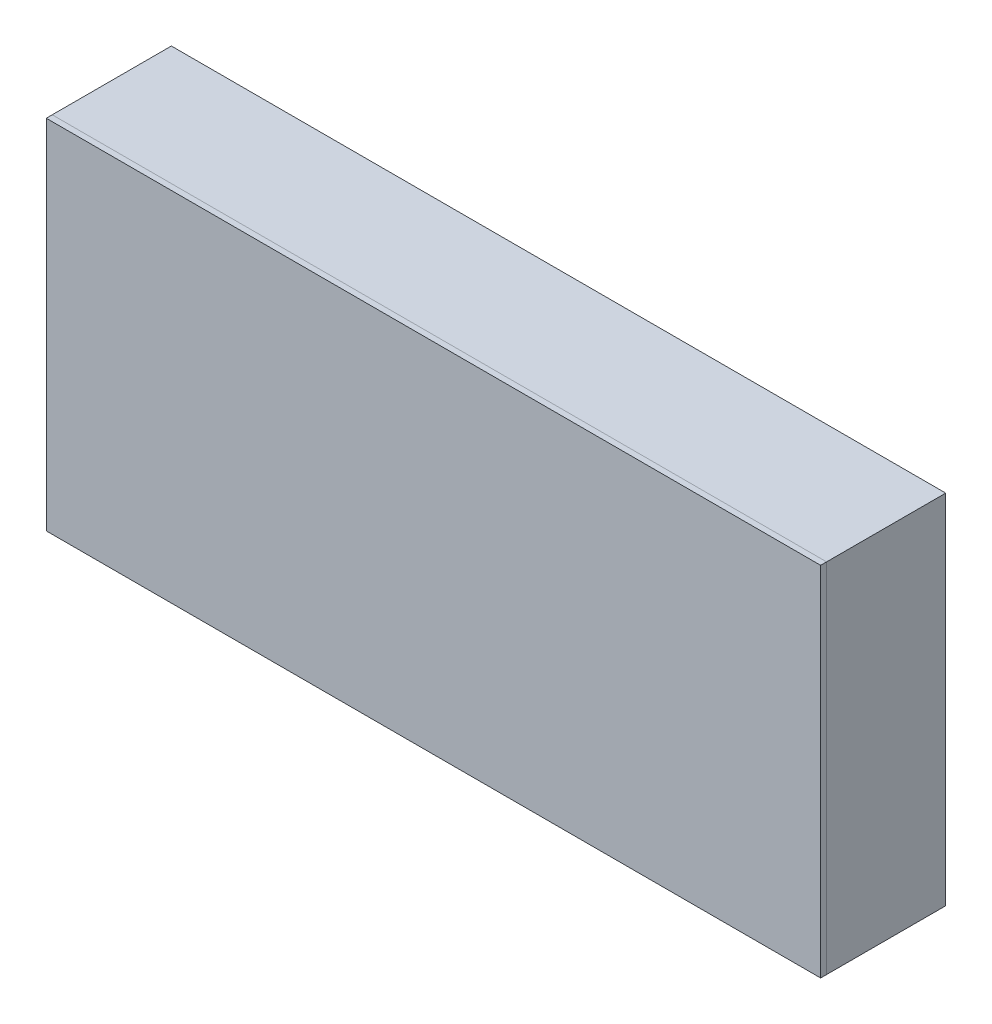
from build123d import *

# Parameters (mm, degrees)
EXTRUDE_THIN1_DEPTH = 20
EXTRUDE_THIN2_DEPTH = 1
SKETCH2_W           = 2
SKETCH2_H           = 17
EXTRUDE_THIN3_DEPTH = 6
BOSS_EXTRUDE1_DEPTH = 2
SKETCH4_W           = 130
SKETCH4_H           = 60
SKETCH4_W_2         = 126
SKETCH4_H_2         = 56
SKETCH4_W_3         = 125.5
SKETCH4_H_3         = 55.5
BOSS_EXTRUDE2_DEPTH = 1
SKETCH4_4_W         = 125.5
SKETCH4_4_H         = 55.5
SKETCH4_4_W_2       = 121.5
SKETCH4_4_H_2       = 51.5
EXTRUDE_THIN4_DEPTH = 5


with BuildPart() as part:
    # Sketch1 → Extrude-Thin1 (new body)
    with BuildSketch(Plane.XY):
        Polygon((-65, -8.999635986), (-65, -30), (65, -30), (65, 30), (-65, 30), (-65, 8.000364014), (-63, 8.000364014), (-63, 28), (63, 28), (63, -28), (-63, -28), (-63, -8.999635986), align=None)
    extrude(amount=EXTRUDE_THIN1_DEPTH)

    # Sketch1_2 → Extrude-Thin2 (add)
    with BuildSketch(Plane.XY):
        Polygon((-65, -8.999635986), (-65, -30), (65, -30), (65, 30), (-65, 30), (-65, 8.000364014), (-53, 8.000364014), (-53, 18), (53, 18), (53, -18), (-53, -18), (-53, -8.999635986), align=None)
    extrude(amount=EXTRUDE_THIN2_DEPTH)



with BuildPart() as body_2:
    # Sketch2 → Extrude-Thin3 (new body)
    with BuildSketch(Plane.XY.offset(14)):
        with Locations((-64, -0.499635986)):
            Rectangle(SKETCH2_W, SKETCH2_H)
    extrude(amount=EXTRUDE_THIN3_DEPTH)


with BuildPart() as part_1:
    add(part.part)

    add(body_2.part)  # Boss-Extrude1 merges body 2
    # Sketch3 → Boss-Extrude1 (add)
    with BuildSketch(Plane(origin=(-63, 0, 0), x_dir=(0, 0, -1), z_dir=(1, 0, 0))):
        Polygon((-14, -6.999635986), (-12, -8.999635986), (-14, -8.999635986), align=None)
        Polygon((-14, 6.000364014), (-12, 8.000364014), (-14, 8.000364014), align=None)
    extrude(amount=-BOSS_EXTRUDE1_DEPTH)


with BuildPart() as body_2_2:
    # Sketch4 → Boss-Extrude2 (new body)
    with BuildSketch(Plane.XY.offset(20)):
        Rectangle(SKETCH4_W, SKETCH4_H)
        Rectangle(SKETCH4_W_2, SKETCH4_H_2, mode=Mode.SUBTRACT)
        Rectangle(SKETCH4_W_2, SKETCH4_H_2)
        Rectangle(SKETCH4_W_3, SKETCH4_H_3, mode=Mode.SUBTRACT)
        Rectangle(SKETCH4_W_3, SKETCH4_H_3)
        Rectangle(SKETCH4_W, SKETCH4_H)
    extrude(amount=BOSS_EXTRUDE2_DEPTH)

    # Sketch4_4 → Extrude-Thin4 (add)
    with BuildSketch(Plane.XY.offset(20)):
        Rectangle(SKETCH4_4_W, SKETCH4_4_H)
        Rectangle(SKETCH4_4_W_2, SKETCH4_4_H_2, mode=Mode.SUBTRACT)
    extrude(amount=-EXTRUDE_THIN4_DEPTH)


solid = Compound([part_1.part, body_2_2.part])
